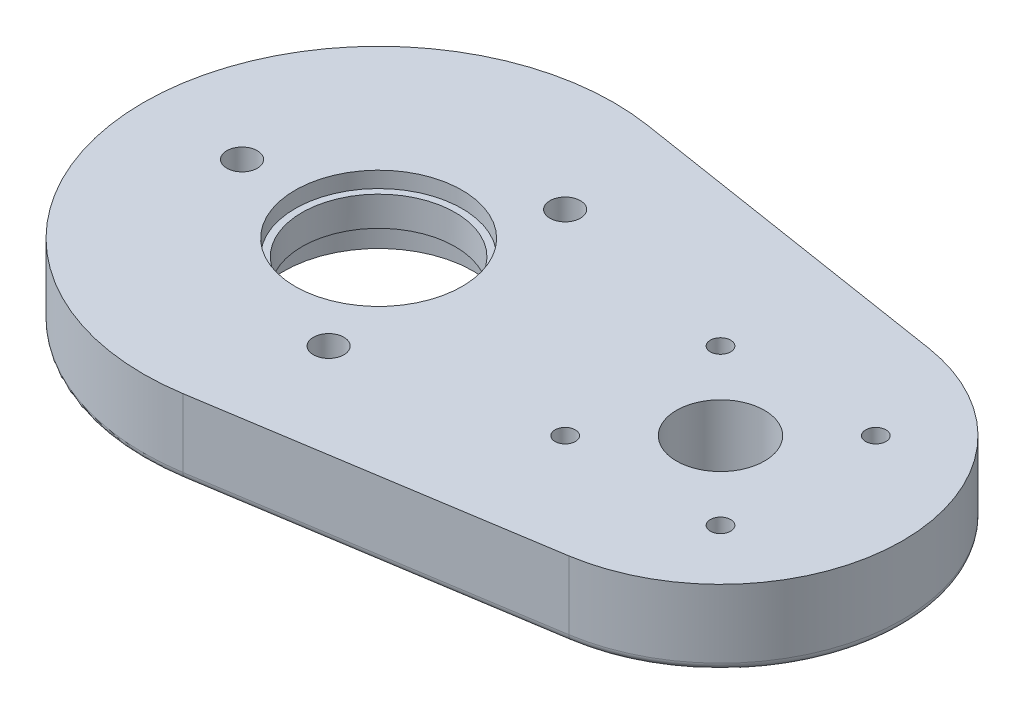
from build123d import *

# Parameters (mm, degrees)
BOSS_EXTRUDE1_DEPTH                          = 12.7
SKETCH2_R                                    = 12.827
SKETCH2_R_2                                  = 7.366
CUT_EXTRUDE1_DEPTH                           = 13.7
CBORE_FOR_10_SOCKET_HEAD_CAP_SCREW1_AT_COUNT = 2
CBORE_FOR_10_SOCKET_HEAD_CAP_SCREW1_AT_PITCH = 39.594681461
CBORE_FOR_10_SOCKET_HEAD_CAP_SCREW1_2_COUNT  = 2
CBORE_FOR_10_SOCKET_HEAD_CAP_SCREW1_2_PITCH  = 39.594681461
CBORE_FOR_M3_SHCS1_AT_2_COUNT                = 2
CBORE_FOR_M3_SHCS1_AT_2_PITCH                = 36.769552622
CBORE_FOR_M3_SHCS1_AT_3_COUNT                = 2
CBORE_FOR_M3_SHCS1_AT_3_PITCH                = 26
CBORE_FOR_M3_SHCS1_AT_4_COUNT                = 2
CBORE_FOR_M3_SHCS1_AT_4_PITCH                = 26
FILLET1_R                                    = 1.27
SKETCH13_R                                   = 15.875
SKETCH13_R_2                                 = 12.827
BEARING_POCKET_DEPTH                         = 5.08
SKETCH14_R                                   = 13.97
SKETCH14_R_2                                 = 12.827
CUT_EXTRUDE3_DEPTH                           = 2.667


with BuildPart() as part:
    # Sketch1 → Boss-Extrude1 (new body)
    with BuildSketch(Plane(origin=(0, 0, 0), x_dir=(1, 0, 0), z_dir=(0, 1, 0))):
        with BuildLine():
            Line((-51.110132534, 38.892037987), (4.735019973, 30.109964893))
            ThreePointArc((4.735019973, 30.109964893), (30.48, 0), (4.735019973, -30.109964893))
            Line((4.735019973, -30.109964893), (-51.110132534, -38.892037987))
            ThreePointArc((-51.110132534, -38.892037987), (-96.5962, 0), (-51.110132534, 38.892037987))
        make_face()
    extrude(amount=BOSS_EXTRUDE1_DEPTH)

    # Sketch2 → Cut-Extrude1 (cut, through all)
    with BuildSketch(Plane(origin=(0, 12.7, 0), x_dir=(1, 0, 0), z_dir=(0, 1, 0))):
        with Locations((-57.2262, 0)):
            Circle(SKETCH2_R)
        Circle(SKETCH2_R_2)
    extrude(amount=-CUT_EXTRUDE1_DEPTH, mode=Mode.SUBTRACT)

    # Sketch12 → CBORE for #10 Socket Head Cap Screw1 (revolve, cut)
    with BuildSketch(Plane(origin=(-80.0862, 0, 0), x_dir=(0, 0, -1), z_dir=(1, 0, 0))):
        Polygon((0, 0), (0, 12.7), (2.5527, 12.7), (2.5527, 4.826), (4.7625, 4.826), (4.7625, 0.635), (5.3975, 0), align=None)
    cbore_for_10_socket_head_cap_screw1 = revolve(axis=Axis((-80.0862, -6.35, 0), (0, 1, 0)), mode=Mode.SUBTRACT)

    # CBORE for #10 Socket Head Cap Screw1 at: CBORE for #10 Socket Head Cap Screw1 ×2
    with Locations(*[Vector(0.866025404, 0, -0.5) * (i * CBORE_FOR_10_SOCKET_HEAD_CAP_SCREW1_AT_PITCH) for i in range(1, CBORE_FOR_10_SOCKET_HEAD_CAP_SCREW1_AT_COUNT)]):
        add(cbore_for_10_socket_head_cap_screw1, mode=Mode.SUBTRACT)

    # CBORE for _10 Socket Head Cap Screw1 2: CBORE for #10 Socket Head Cap Screw1 ×2
    with Locations(*[Vector(0.866025404, 0, 0.5) * (i * CBORE_FOR_10_SOCKET_HEAD_CAP_SCREW1_2_PITCH) for i in range(1, CBORE_FOR_10_SOCKET_HEAD_CAP_SCREW1_2_COUNT)]):
        add(cbore_for_10_socket_head_cap_screw1, mode=Mode.SUBTRACT)

    # Sketch16 → CBORE for M3 SHCS1 (revolve, cut)
    with BuildSketch(Plane(origin=(-13, 0, -13), x_dir=(0, 0, -1), z_dir=(1, 0, 0))):
        Polygon((0, 0), (0, 12.7), (1.7, 12.7), (1.7, 3), (3.25, 3), (3.25, 0.75), (4, 0), align=None)
    cbore_for_m3_shcs1 = revolve(axis=Axis((-13, -6.35, -13), (0, 1, 0)), mode=Mode.SUBTRACT)

    # CBORE for M3 SHCS1 at 2: CBORE for M3 SHCS1 ×2
    with Locations(*[Vector(0.707106781, 0, 0.707106781) * (i * CBORE_FOR_M3_SHCS1_AT_2_PITCH) for i in range(1, CBORE_FOR_M3_SHCS1_AT_2_COUNT)]):
        add(cbore_for_m3_shcs1, mode=Mode.SUBTRACT)

    # CBORE for M3 SHCS1 at 3: CBORE for M3 SHCS1 ×2
    with Locations(*[(i * CBORE_FOR_M3_SHCS1_AT_3_PITCH, 0, 0) for i in range(1, CBORE_FOR_M3_SHCS1_AT_3_COUNT)]):
        add(cbore_for_m3_shcs1, mode=Mode.SUBTRACT)

    # CBORE for M3 SHCS1 at 4: CBORE for M3 SHCS1 ×2
    with Locations(*[(0, 0, i * CBORE_FOR_M3_SHCS1_AT_4_PITCH) for i in range(1, CBORE_FOR_M3_SHCS1_AT_4_COUNT)]):
        add(cbore_for_m3_shcs1, mode=Mode.SUBTRACT)

    # Fillet1
    fillet1_edges = [part.edges().sort_by_distance(p)[0] for p in [
        (-7.366, 0, 0),
        (-23.187556281, 0, -34.50100144),
        (30.48, 0, 0),
        (-23.187556281, 0, 34.50100144),
        (-96.5962, 0, 0),
    ]]
    fillet(fillet1_edges, radius=FILLET1_R)

    # Sketch13 → bearing_pocket (cut)
    with BuildSketch(Plane.XZ):
        with Locations((-57.2262, 0)):
            Circle(SKETCH13_R)
        with Locations((-57.2262, 0)):
            Circle(SKETCH13_R_2, mode=Mode.SUBTRACT)
    extrude(amount=-BEARING_POCKET_DEPTH, mode=Mode.SUBTRACT)

    # Sketch14 → Cut-Extrude3 (cut)
    with BuildSketch(Plane(origin=(0, 12.7, 0), x_dir=(1, 0, 0), z_dir=(0, 1, 0))):
        with Locations((-57.2262, 0)):
            Circle(SKETCH14_R)
        with Locations((-57.2262, 0)):
            Circle(SKETCH14_R_2, mode=Mode.SUBTRACT)
    extrude(amount=-CUT_EXTRUDE3_DEPTH, mode=Mode.SUBTRACT)


solid = part.part
